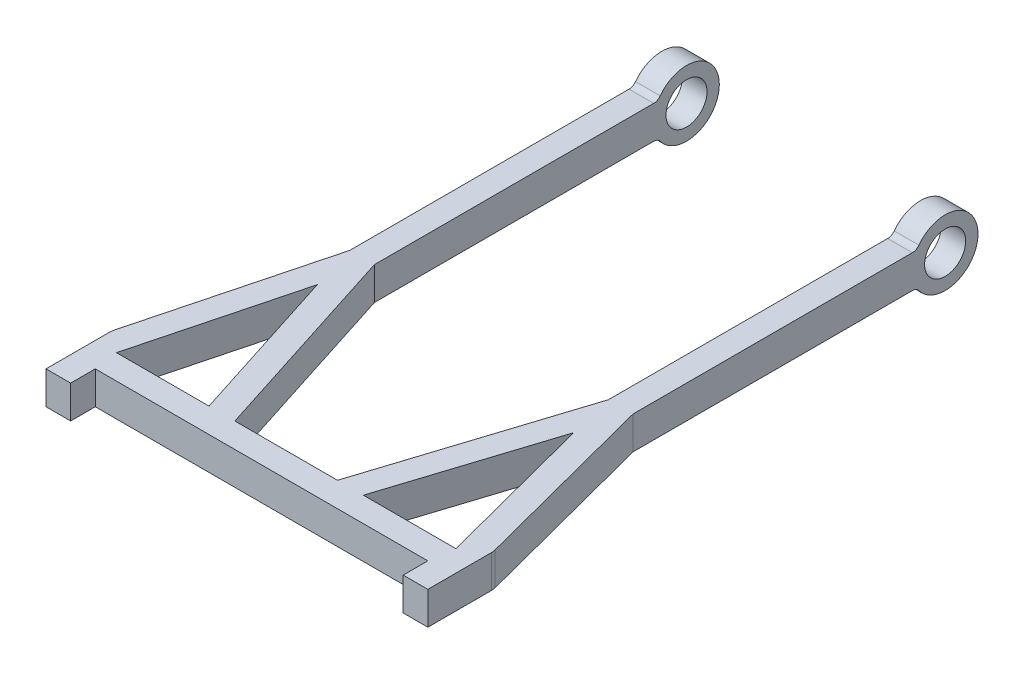
from build123d import *

# Parameters (mm, degrees)
BOSS_EXTRUDE1_DEPTH     = 1
BOSS_EXTRUDE2_START     = 7.125
BOSS_EXTRUDE2_DEPTH     = 1.5
BOSS_EXTRUDE3_START     = -8.625
BOSS_EXTRUDE3_DEPTH     = 1.5
SKETCH3_R               = 1.25
CUT_EXTRUDE1_DEPTH      = 12.625
CUT_EXTRUDE1_DEPTH_BACK = 12.625


with BuildPart() as part:
    # Sketch1 → Boss-Extrude1 (new body, symmetric)
    with BuildSketch(Plane(origin=(0, 0, 0), x_dir=(1, 0, 0), z_dir=(0, 1, 0))):
        with BuildLine():
            Line((-10.125, -0.75), (0, -0.75))
            Line((0, -0.75), (0, 0.75))
            Line((0, 0.75), (-3.125, 0.75))
            Line((-3.125, 0.75), (-7.125, 13.25))
            Line((-7.125, 13.25), (-7.125, 30.25))
            Line((-7.125, 30.25), (-8.625, 30.25))
            Line((-8.625, 30.25), (-8.625, 13.25))
            Line((-8.625, 13.25), (-11.592617272, 1.874133789))
            ThreePointArc((-11.592617272, 1.874133789), (-11.61687128, 1.748957182), (-11.625, 1.621711892))
            Line((-11.625, 1.621711892), (-11.625, -0.75))
            Line((-11.625, -0.75), (-11.625, -2.25))
            Line((-11.625, -2.25), (-10.125, -2.25))
            Line((-10.125, -2.25), (-10.125, -0.75))
        make_face()
        Polygon((-4.69992857, 0.75), (-7.804648328, 10.452249246), (-10.335669871, 0.75), align=None, mode=Mode.SUBTRACT)
    boss_extrude1 = extrude(amount=BOSS_EXTRUDE1_DEPTH, both=True)

    # Mirror1: Boss-Extrude1 across plane
    add(boss_extrude1.mirror(Plane(origin=(0, 0, 0), x_dir=(0, 0, 1), z_dir=(1, 0, 0))))

    # Sketch2 → Boss-Extrude2 (add)
    with BuildSketch(Plane(origin=(0, 0, 0), x_dir=(0, 0, -1), z_dir=(1, 0, 0)).offset(BOSS_EXTRUDE2_START)):
        with BuildLine():
            Line((30.25, 1), (30.25, -1))
            ThreePointArc((30.25, -1), (30.473606798, -1.052786405), (30.65, -1.2))
            ThreePointArc((30.65, -1.2), (34.25, 0), (30.65, 1.2))
            ThreePointArc((30.65, 1.2), (30.473606798, 1.052786405), (30.25, 1))
        make_face()
    extrude(amount=BOSS_EXTRUDE2_DEPTH)

    # Sketch2_2 → Boss-Extrude3 (add)
    with BuildSketch(Plane(origin=(0, 0, 0), x_dir=(0, 0, -1), z_dir=(1, 0, 0)).offset(BOSS_EXTRUDE3_START)):
        with BuildLine():
            Line((30.25, 1), (30.25, -1))
            ThreePointArc((30.25, -1), (30.473606798, -1.052786405), (30.65, -1.2))
            ThreePointArc((30.65, -1.2), (34.25, 0), (30.65, 1.2))
            ThreePointArc((30.65, 1.2), (30.473606798, 1.052786405), (30.25, 1))
        make_face()
    extrude(amount=BOSS_EXTRUDE3_DEPTH)

    # Sketch3 → Cut-Extrude1 (cut, two sides)
    with BuildSketch(Plane(origin=(0, 0, 0), x_dir=(0, 0, -1), z_dir=(1, 0, 0))) as cut_extrude1_sk:
        with Locations((32.25, 0)):
            Circle(SKETCH3_R)
    extrude(amount=CUT_EXTRUDE1_DEPTH, mode=Mode.SUBTRACT)
    extrude(cut_extrude1_sk.sketch, amount=-CUT_EXTRUDE1_DEPTH_BACK, mode=Mode.SUBTRACT)


solid = part.part
